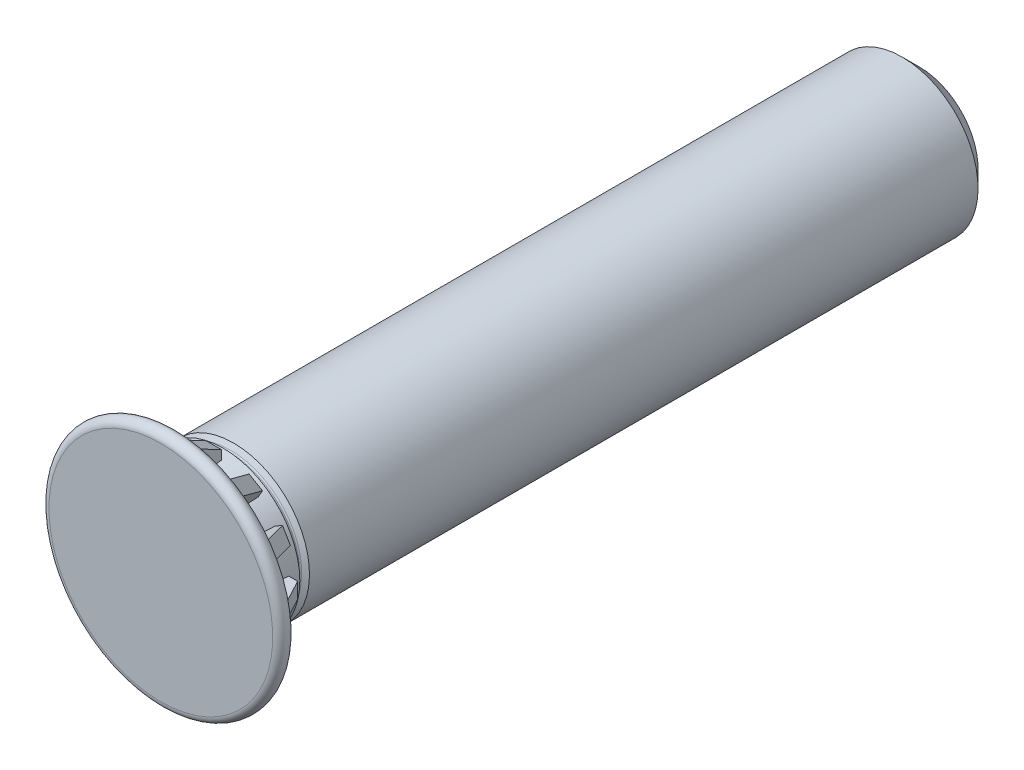
from build123d import *

# Parameters (mm, degrees)
FILLET2_R           = 0.04375
SKETCH16_R          = 1.507448052
CUT_EXTRUDE3_DEPTH  = 0.175
CUT_EXTRUDE3_DRAFT  = -30
BOSS_EXTRUDE1_DEPTH = 0.20475
CIRPATTERN3_COUNT   = 12
SKETCH14_R          = 2.320854115
BOSS_EXTRUDE3_DEPTH = 0.15


with BuildPart() as part:
    # Sketch7 → Revolve3 (revolve)
    with BuildSketch(Plane(origin=(0, 0, 0), x_dir=(0, 0, -1), z_dir=(1, 0, 0))):
        with BuildLine():
            Line((10, 1.545336663), (9.545336663, 2))
            Line((9.545336663, 2), (-8.0815625, 2))
            Line((-8.0815625, 2), (-8.1690625, 1.848445554))
            Line((-8.1690625, 1.848445554), (-8.2565625, 1.848445554))
            Line((-8.2565625, 1.848445554), (-8.355, 2.018944306))
            Line((-8.355, 2.018944306), (-9.6, 1.848445554))
            Line((-9.6, 1.848445554), (-9.6, 2))
            Line((-9.6, 2), (-9.6, 2.95))
            ThreePointArc((-9.6, 2.95), (-9.8, 3.15), (-10, 2.95))
            Line((-10, 2.95), (-10, 0))
            Line((-10, 0), (10, 0))
            Line((10, 0), (10, 1.545336663))
        make_face()
    revolve(axis=Axis((0, 0, -10), (0, 0, 1)))

    # Fillet2
    fillet2_edges = [part.edges().sort_by_distance(p)[0] for p in [
        (0, -1.848445554, 8.2565625),
        (0, -1.848445554, 8.1690625),
    ]]
    fillet(fillet2_edges, radius=FILLET2_R)


with BuildPart() as cut_extrude3_tool:
    # Sketch16 → Cut-Extrude3 (with draft: the straight prism first)
    with BuildSketch(Plane(origin=(0, 0, -10), x_dir=(-1, 0, 0), z_dir=(0, 0, -1))):
        Circle(SKETCH16_R)
    extrude(amount=-CUT_EXTRUDE3_DEPTH)
    # Cut-Extrude3: the draft: its side faces are tilted about the plane it starts from
    cut_extrude3_sides = [cut_extrude3_tool.faces().sort_by_distance(p)[0] for p in [
        (1.507448052, 0, -9.9125),
    ]]
    draft(cut_extrude3_sides, Plane(origin=(0, 0, -10), x_dir=(-1, 0, 0), z_dir=(0, 0, -1)), CUT_EXTRUDE3_DRAFT)


with BuildPart() as part_1:
    add(part.part)

    # Cut-Extrude3: cut by cut_extrude3_tool
    add(cut_extrude3_tool.part, mode=Mode.SUBTRACT)

    # Cut-Extrude1 cone 1 section (through the dimple's axis) → Cut-Extrude1 (revolve, cut)
    with BuildSketch(Plane(origin=(0, 0, -9.825), x_dir=(0, 1, 0), z_dir=(1, 0, 0))):
        Polygon((0, 0), (0.5, 0), (0, 0.5), align=None)
    revolve(axis=Axis((0, 0, -9.825), (0, 0, 1)), mode=Mode.SUBTRACT)

    # Sketch9 → Boss-Extrude1 (add, symmetric)
    with BuildSketch(Plane(origin=(0, 0, 0), x_dir=(0, 0, -1), z_dir=(1, 0, 0))):
        Polygon((-9.6, 2.578726794), (-9.3, 2.578726794), (-8.6, 2.207453588), (-8.6, 0), (-9.6, 0), align=None)
    boss_extrude1 = extrude(amount=BOSS_EXTRUDE1_DEPTH, both=True)

    # CirPattern3: Boss-Extrude1 ×12 about axis
    cirpattern3_axis = Axis((0, 0, 0), (0, 0, 1))
    for i in range(1, CIRPATTERN3_COUNT):
        add(boss_extrude1.rotate(cirpattern3_axis, i * 360 / CIRPATTERN3_COUNT))

    # Sketch14 → Boss-Extrude3 (add)
    with BuildSketch(Plane(origin=(0, 0, 9.6), x_dir=(-1, 0, 0), z_dir=(0, 0, -1))):
        Circle(SKETCH14_R)
    extrude(amount=BOSS_EXTRUDE3_DEPTH)


solid = part_1.part
